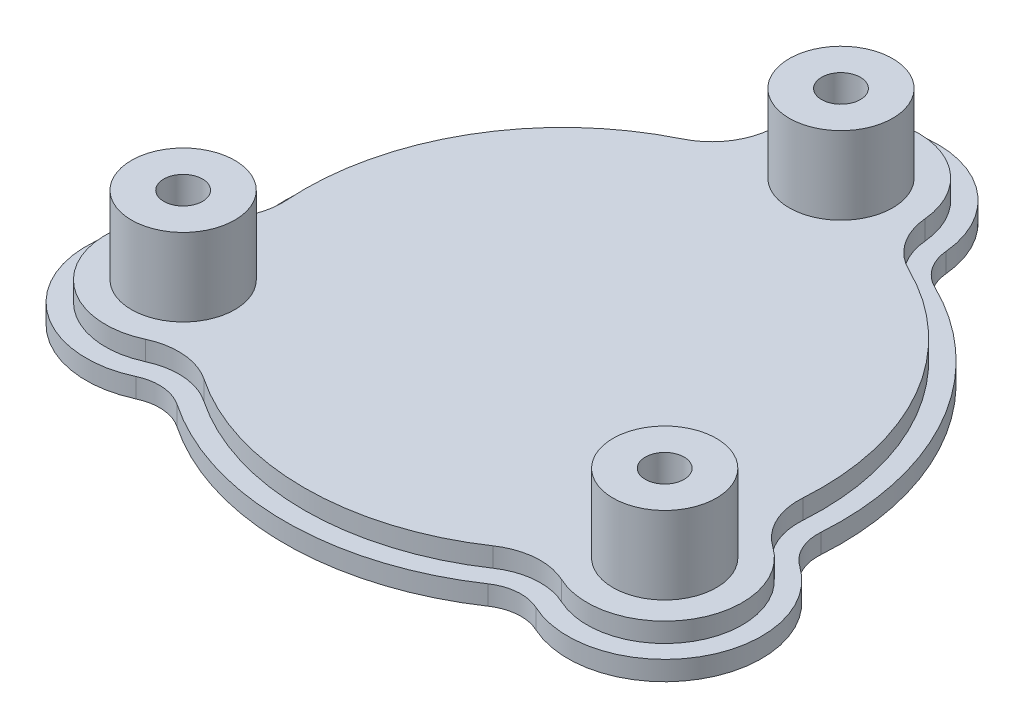
from build123d import *

# Parameters (mm, degrees)
BOSS_EXTRUDE3_DEPTH = 3
SKETCH1_5_R         = 8
BOSS_EXTRUDE4_DEPTH = 6
SKETCH1_6_R         = 8
BOSS_EXTRUDE5_DEPTH = 18
SKETCH1_7_R         = 6
CUT_EXTRUDE1_DEPTH  = 12
SKETCH1_8_R         = 3
CUT_EXTRUDE2_DEPTH  = 125


with BuildPart() as part:
    # Sketch1 → Boss-Extrude3 (new body)
    with BuildSketch(Plane(origin=(0, 0, 0), x_dir=(1, 0, 0), z_dir=(0, 1, 0))):
        with BuildLine():
            ThreePointArc((-14.941453584, 44.323995772), (-16.147655157, 40.973517523), (-18.846153454, 38.65))
            ThreePointArc((-18.846153454, 38.65), (-37.239092363, 21.5), (-42.894958583, -3.003752345))
            ThreePointArc((-42.894958583, -3.003752345), (-43.557934635, -6.502479184), (-45.856433127, -9.222319513))
            ThreePointArc((-45.856433127, -9.222319513), (-50.229473419, -29), (-30.914979544, -35.101676259))
            ThreePointArc((-30.914979544, -35.101676259), (-27.410279478, -34.471038339), (-24.048805129, -35.646247655))
            ThreePointArc((-24.048805129, -35.646247655), (0, -43), (24.048805129, -35.646247655))
            ThreePointArc((24.048805129, -35.646247655), (27.410279478, -34.471038339), (30.914979544, -35.101676259))
            ThreePointArc((30.914979544, -35.101676259), (50.229473419, -29), (45.856433127, -9.222319513))
            ThreePointArc((45.856433127, -9.222319513), (43.557934635, -6.502479184), (42.894958583, -3.003752345))
            ThreePointArc((42.894958583, -3.003752345), (37.239092363, 21.5), (18.846153454, 38.65))
            ThreePointArc((18.846153454, 38.65), (16.147655157, 40.973517523), (14.941453584, 44.323995772))
            ThreePointArc((14.941453584, 44.323995772), (0, 58), (-14.941453584, 44.323995772))
        make_face()
        with BuildLine():
            ThreePointArc((-39.902287054, -2.794188228), (-34.641016151, 20), (-17.531305538, 35.953488372))
            ThreePointArc((-17.531305538, 35.953488372), (-13.676307972, 39.272799119), (-11.953162867, 44.059196617))
            ThreePointArc((-11.953162867, 44.059196617), (0, 55), (11.953162867, 44.059196617))
            ThreePointArc((11.953162867, 44.059196617), (13.676307972, 39.272799119), (17.531305538, 35.953488372))
            ThreePointArc((17.531305538, 35.953488372), (34.641016151, 20), (39.902287054, -2.794188228))
            ThreePointArc((39.902287054, -2.794188228), (40.8493957, -7.792369426), (44.132964974, -11.67785561))
            ThreePointArc((44.132964974, -11.67785561), (47.631397208, -27.5), (32.179802107, -32.381341007))
            ThreePointArc((32.179802107, -32.381341007), (27.173087728, -31.480429693), (22.370981516, -33.159300144))
            ThreePointArc((22.370981516, -33.159300144), (0, -40), (-22.370981516, -33.159300144))
            ThreePointArc((-22.370981516, -33.159300144), (-27.173087728, -31.480429693), (-32.179802107, -32.381341007))
            ThreePointArc((-32.179802107, -32.381341007), (-47.631397208, -27.5), (-44.132964974, -11.67785561))
            ThreePointArc((-44.132964974, -11.67785561), (-40.8493957, -7.792369426), (-39.902287054, -2.794188228))
        make_face(mode=Mode.SUBTRACT)
    extrude(amount=BOSS_EXTRUDE3_DEPTH)

    # Sketch1_5 → Boss-Extrude4 (add)
    with BuildSketch(Plane(origin=(0, 0, 0), x_dir=(1, 0, 0), z_dir=(0, 1, 0))):
        with BuildLine():
            ThreePointArc((-11.953162867, 44.059196617), (-13.676307972, 39.272799119), (-17.531305538, 35.953488372))
            ThreePointArc((-17.531305538, 35.953488372), (-34.641016151, 20), (-39.902287054, -2.794188228))
            ThreePointArc((-39.902287054, -2.794188228), (-40.8493957, -7.792369426), (-44.132964974, -11.67785561))
            ThreePointArc((-44.132964974, -11.67785561), (-47.631397208, -27.5), (-32.179802107, -32.381341007))
            ThreePointArc((-32.179802107, -32.381341007), (-27.173087728, -31.480429693), (-22.370981516, -33.159300144))
            ThreePointArc((-22.370981516, -33.159300144), (0, -40), (22.370981516, -33.159300144))
            ThreePointArc((22.370981516, -33.159300144), (27.173087728, -31.480429693), (32.179802107, -32.381341007))
            ThreePointArc((32.179802107, -32.381341007), (47.631397208, -27.5), (44.132964974, -11.67785561))
            ThreePointArc((44.132964974, -11.67785561), (40.8493957, -7.792369426), (39.902287054, -2.794188228))
            ThreePointArc((39.902287054, -2.794188228), (34.641016151, 20), (17.531305538, 35.953488372))
            ThreePointArc((17.531305538, 35.953488372), (13.676307972, 39.272799119), (11.953162867, 44.059196617))
            ThreePointArc((11.953162867, 44.059196617), (0, 55), (-11.953162867, 44.059196617))
        make_face()
        with Locations((-37.239092363, -21.5)):
            Circle(SKETCH1_5_R, mode=Mode.SUBTRACT)
        with Locations((37.239092363, -21.5)):
            Circle(SKETCH1_5_R, mode=Mode.SUBTRACT)
        with Locations((0, 43)):
            Circle(SKETCH1_5_R, mode=Mode.SUBTRACT)
    extrude(amount=BOSS_EXTRUDE4_DEPTH)

    # Sketch1_6 → Boss-Extrude5 (add)
    with BuildSketch(Plane(origin=(0, 0, 0), x_dir=(1, 0, 0), z_dir=(0, 1, 0))):
        with Locations((0, 43)):
            Circle(SKETCH1_6_R)
        with Locations((-37.239092363, -21.5)):
            Circle(SKETCH1_6_R)
        with Locations((37.239092363, -21.5)):
            Circle(SKETCH1_6_R)
    extrude(amount=BOSS_EXTRUDE5_DEPTH)

    # Sketch1_7 → Cut-Extrude1 (cut)
    with BuildSketch(Plane(origin=(0, 0, 0), x_dir=(1, 0, 0), z_dir=(0, 1, 0))):
        with Locations((0, 43)):
            Circle(SKETCH1_7_R)
        with Locations((37.239092363, -21.5)):
            Circle(SKETCH1_7_R)
        with Locations((-37.239092363, -21.5)):
            Circle(SKETCH1_7_R)
    extrude(amount=CUT_EXTRUDE1_DEPTH, mode=Mode.SUBTRACT)

    # Sketch1_8 → Cut-Extrude2 (cut)
    with BuildSketch(Plane(origin=(0, 0, 0), x_dir=(1, 0, 0), z_dir=(0, 1, 0))):
        with Locations((0, 43)):
            Circle(SKETCH1_8_R)
        with Locations((37.239092363, -21.5)):
            Circle(SKETCH1_8_R)
        with Locations((-37.239092363, -21.5)):
            Circle(SKETCH1_8_R)
    extrude(amount=CUT_EXTRUDE2_DEPTH, mode=Mode.SUBTRACT)


solid = part.part
